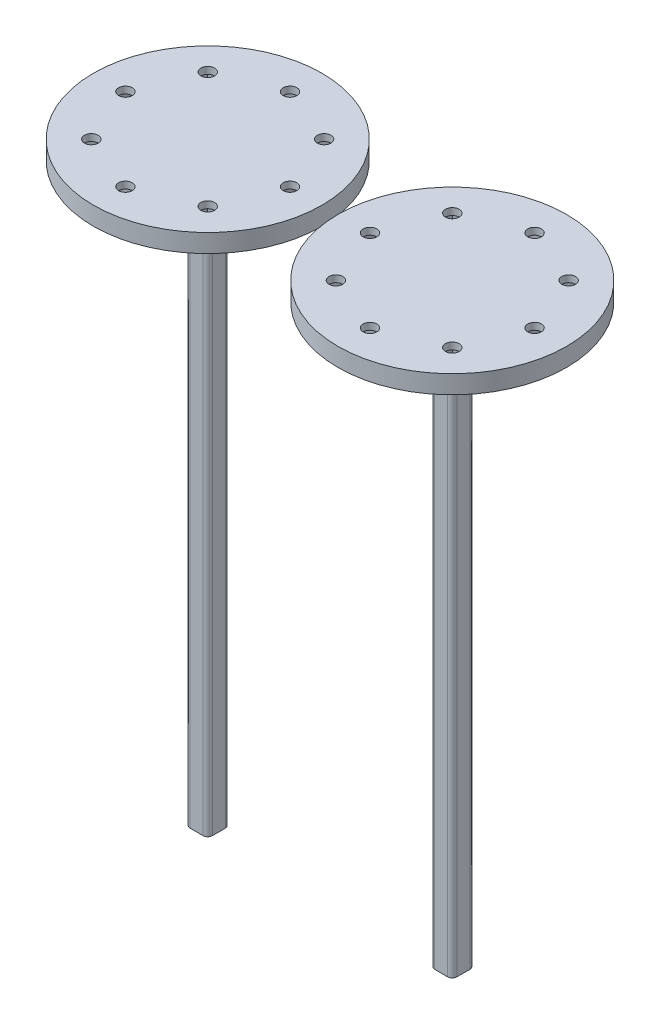
from build123d import *

# Parameters (mm, degrees)
SKETCH_1_R               = 20
EXTRUDE_1_DEPTH          = 4
SKETCH_2_R               = 7.407075634
EXTRUDE_2_DEPTH          = 8
SKETCH_3_W               = 4.85
SKETCH_3_H               = 4.85
EXTRUDE_3_DEPTH          = 118
SKETCH_5_R               = 25
EXTRUDE_4_DEPTH          = 4
CUT_EXTRUDE_1_DEPTH      = 2.5
SKETCH_7_R               = 1.5
CUT_EXTRUDE_2_DEPTH      = 2.5
PATTERN_CIRCULAR_1_COUNT = 8
FILLET_1_R               = 1
SKETCH_9_R               = 25
EXTRUDE_5_DEPTH          = 4
SKETCH_10_R              = 5.5
EXTRUDE_6_DEPTH          = 8
SKETCH_11_W              = 4.85
SKETCH_11_H              = 4.85
EXTRUDE_7_DEPTH          = 118
CUT_EXTRUDE_7_DEPTH      = 128.5
SKETCH_13_R              = 1.5
CUT_EXTRUDE_8_DEPTH      = 128.5
PATTERN_CIRCULAR_2_COUNT = 8
FILLET_2_R               = 1
SKETCH_14_R              = 7.407075634
SKETCH_14_R_2            = 5.5
CUT_EXTRUDE_9_DEPTH      = 8


with BuildPart() as part:
    # 草图1 → 凸台-拉伸1 (new body)
    with BuildSketch(Plane(origin=(0, 0, 0), x_dir=(1, 0, 0), z_dir=(0, 1, 0))):
        Circle(SKETCH_1_R)
    extrude(amount=EXTRUDE_1_DEPTH)

    # 草图2 → 凸台-拉伸2 (add)
    with BuildSketch(Plane.XZ):
        Circle(SKETCH_2_R)
    extrude(amount=EXTRUDE_2_DEPTH)

    # 草图3 → 凸台-拉伸3 (add)
    with BuildSketch(Plane.XZ.offset(8)):
        Rectangle(SKETCH_3_W, SKETCH_3_H)
    extrude(amount=EXTRUDE_3_DEPTH)

    # 草图5 → 凸台-拉伸4 (add)
    with BuildSketch(Plane(origin=(0, 4, 0), x_dir=(1, 0, 0), z_dir=(0, 1, 0))):
        Circle(SKETCH_5_R)
    extrude(amount=-EXTRUDE_4_DEPTH)

    # 草图6 → 切除-拉伸1 (cut)
    with BuildSketch(Plane.XZ):
        Polygon((21.233161507, 0), (19.616580754, 2.8), (16.383419246, 2.8), (14.766838493, 0), (16.383419246, -2.8), (19.616580754, -2.8), align=None)
    cut_extrude_1 = extrude(amount=-CUT_EXTRUDE_1_DEPTH, mode=Mode.SUBTRACT)

    # 草图7 → 切除-拉伸2 (cut)
    with BuildSketch(Plane.XZ.offset(-2.5)):
        with Locations((18, 0)):
            Circle(SKETCH_7_R)
    cut_extrude_2 = extrude(amount=-CUT_EXTRUDE_2_DEPTH, mode=Mode.SUBTRACT)

    # 阵列(圆周)1: 切除-拉伸1, 切除-拉伸2 ×8 about axis
    pattern_circular_1_axis = Axis((0, 0, 0), (0, 1, 0))
    for i in range(1, PATTERN_CIRCULAR_1_COUNT):
        add(cut_extrude_1.rotate(pattern_circular_1_axis, i * 360 / PATTERN_CIRCULAR_1_COUNT), mode=Mode.SUBTRACT)
        add(cut_extrude_2.rotate(pattern_circular_1_axis, i * 360 / PATTERN_CIRCULAR_1_COUNT), mode=Mode.SUBTRACT)

    # 圆角1
    fillet_1_edges = [part.edges().sort_by_distance(p)[0] for p in [
        (2.425, -67, -2.425),
        (2.425, -67, 2.425),
        (-2.425, -67, 2.425),
        (-2.425, -67, -2.425),
    ]]
    fillet(fillet_1_edges, radius=FILLET_1_R)

    # 草图14 → 切除-拉伸9 (cut)
    with BuildSketch(Plane.XZ.offset(8)):
        Circle(SKETCH_14_R)
        Circle(SKETCH_14_R_2, mode=Mode.SUBTRACT)
    extrude(amount=-CUT_EXTRUDE_9_DEPTH, mode=Mode.SUBTRACT)


with BuildPart() as body_2:
    # 草图9 → 凸台-拉伸5 (new body)
    with BuildSketch(Plane(origin=(0, 0, 0), x_dir=(1, 0, 0), z_dir=(0, 1, 0))):
        with Locations((53.487556259, 0)):
            Circle(SKETCH_9_R)
    extrude(amount=EXTRUDE_5_DEPTH)

    # 草图10 → 凸台-拉伸6 (add)
    with BuildSketch(Plane.XZ):
        with Locations((53.487556259, 0)):
            Circle(SKETCH_10_R)
    extrude(amount=EXTRUDE_6_DEPTH)

    # 草图11 → 凸台-拉伸7 (add)
    with BuildSketch(Plane.XZ.offset(8)):
        with Locations((53.487556259, 0)):
            Rectangle(SKETCH_11_W, SKETCH_11_H)
    extrude(amount=EXTRUDE_7_DEPTH)

    # 草图12 → 切除-拉伸7 (cut)
    with BuildSketch(Plane.XZ.offset(126)):
        Polygon((38.720717767, 0), (37.104137013, 2.8), (33.870975506, 2.8), (32.254394752, 0), (33.870975506, -2.8), (37.104137013, -2.8), align=None)
    cut_extrude_7 = extrude(amount=-CUT_EXTRUDE_7_DEPTH, mode=Mode.SUBTRACT)

    # 草图13 → 切除-拉伸8 (cut)
    with BuildSketch(Plane.XZ.offset(-2.5)):
        with Locations((35.487556259, 0)):
            Circle(SKETCH_13_R)
    cut_extrude_8 = extrude(amount=-CUT_EXTRUDE_8_DEPTH, mode=Mode.SUBTRACT)

    # 阵列(圆周)2: 切除-拉伸7, 切除-拉伸8 ×8 about axis
    pattern_circular_2_axis = Axis((53.487556259, 0, 0), (0, 1, 0))
    for i in range(1, PATTERN_CIRCULAR_2_COUNT):
        add(cut_extrude_7.rotate(pattern_circular_2_axis, i * 360 / PATTERN_CIRCULAR_2_COUNT), mode=Mode.SUBTRACT)
        add(cut_extrude_8.rotate(pattern_circular_2_axis, i * 360 / PATTERN_CIRCULAR_2_COUNT), mode=Mode.SUBTRACT)

    # 圆角2
    fillet_2_edges = [body_2.edges().sort_by_distance(p)[0] for p in [
        (55.912556259, -67, -2.425),
        (55.912556259, -67, 2.425),
        (51.062556259, -67, 2.425),
        (51.062556259, -67, -2.425),
    ]]
    fillet(fillet_2_edges, radius=FILLET_2_R)


solid = Compound([part.part, body_2.part])
